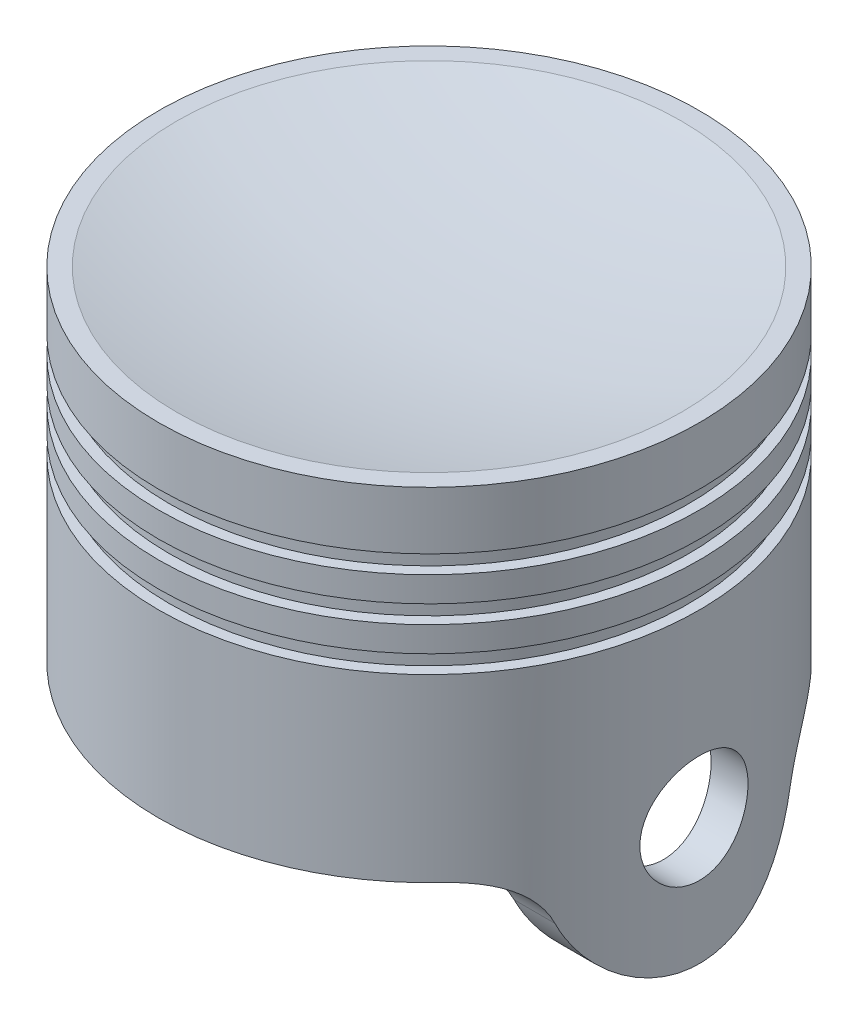
from build123d import *

# Parameters (mm, degrees)
SKETCH2_R               = 7.5
CUT_EXTRUDE1_DEPTH      = 38.5
CUT_EXTRUDE1_DEPTH_BACK = 38.5
CUT_EXTRUDE2_DEPTH      = 38.500000101
CUT_EXTRUDE2_DEPTH_BACK = 38.500000101


with BuildPart() as part:
    # Sketch1 one side → Revolve1 (revolve)
    with BuildSketch(Plane(origin=(0, 0, 0), x_dir=(0, 0, -1), z_dir=(1, 0, 0))):
        with BuildLine():
            Line((-37.5, 15), (-37.5, -37.5))
            Line((-37.5, -37.5), (-32.5, -37.5))
            Line((-32.5, -37.5), (-32.5, 17.5))
            Line((-32.5, 17.5), (0, 17.5))
            Line((0, 17.5), (0, 33))
            ThreePointArc((0, 33), (-17.644049989, 34.1296112), (-35, 37.5))
            Line((-35, 37.5), (-37.5, 37.5))
            Line((-37.5, 37.5), (-37.5, 29.5))
            Line((-37.5, 29.5), (-36, 29.5))
            Line((-36, 29.5), (-36, 27))
            Line((-36, 27), (-37.5, 27))
            Line((-37.5, 27), (-37.5, 23.5))
            Line((-37.5, 23.5), (-36, 23.5))
            Line((-36, 23.5), (-36, 21))
            Line((-36, 21), (-37.5, 21))
            Line((-37.5, 21), (-37.5, 17.5))
            Line((-37.5, 17.5), (-36, 17.5))
            Line((-36, 17.5), (-36, 15))
            Line((-36, 15), (-37.5, 15))
        make_face()
    revolve(axis=Axis((0, 37.5, 0), (0, -1, 0)))

    # Sketch2 → Cut-Extrude1 (cut, two sides)
    with BuildSketch(Plane(origin=(0, 0, 0), x_dir=(0, 0, -1), z_dir=(1, 0, 0))) as cut_extrude1_sk:
        with Locations((0, -10)):
            Circle(SKETCH2_R)
    extrude(amount=CUT_EXTRUDE1_DEPTH, mode=Mode.SUBTRACT)
    extrude(cut_extrude1_sk.sketch, amount=-CUT_EXTRUDE1_DEPTH_BACK, mode=Mode.SUBTRACT)

    # Sketch3 → Cut-Extrude2 (cut, two sides)
    with BuildSketch(Plane(origin=(0, 0, 0), x_dir=(0, 0, -1), z_dir=(1, 0, 0))) as cut_extrude2_sk:
        with BuildLine():
            Line((55.2014237, -46.459477436), (54.298595824, -10))
            Line((54.298595824, -10), (25.617376915, -10))
            ThreePointArc((25.617376915, -10), (19.976616167, -11.742771762), (16.301967128, -16.363636364))
            ThreePointArc((16.301967128, -16.363636364), (0, -27.5), (-16.301967128, -16.363636364))
            ThreePointArc((-16.301967128, -16.363636364), (-19.976616167, -11.742771762), (-25.617376915, -10))
            Line((-25.617376915, -10), (-54.298595824, -10))
            Line((-54.298595824, -10), (-43.079650209, -45.071046523))
            Line((-43.079650209, -45.071046523), (55.2014237, -46.459477436))
        make_face()
    extrude(amount=CUT_EXTRUDE2_DEPTH, mode=Mode.SUBTRACT)
    extrude(cut_extrude2_sk.sketch, amount=-CUT_EXTRUDE2_DEPTH_BACK, mode=Mode.SUBTRACT)


solid = part.part
